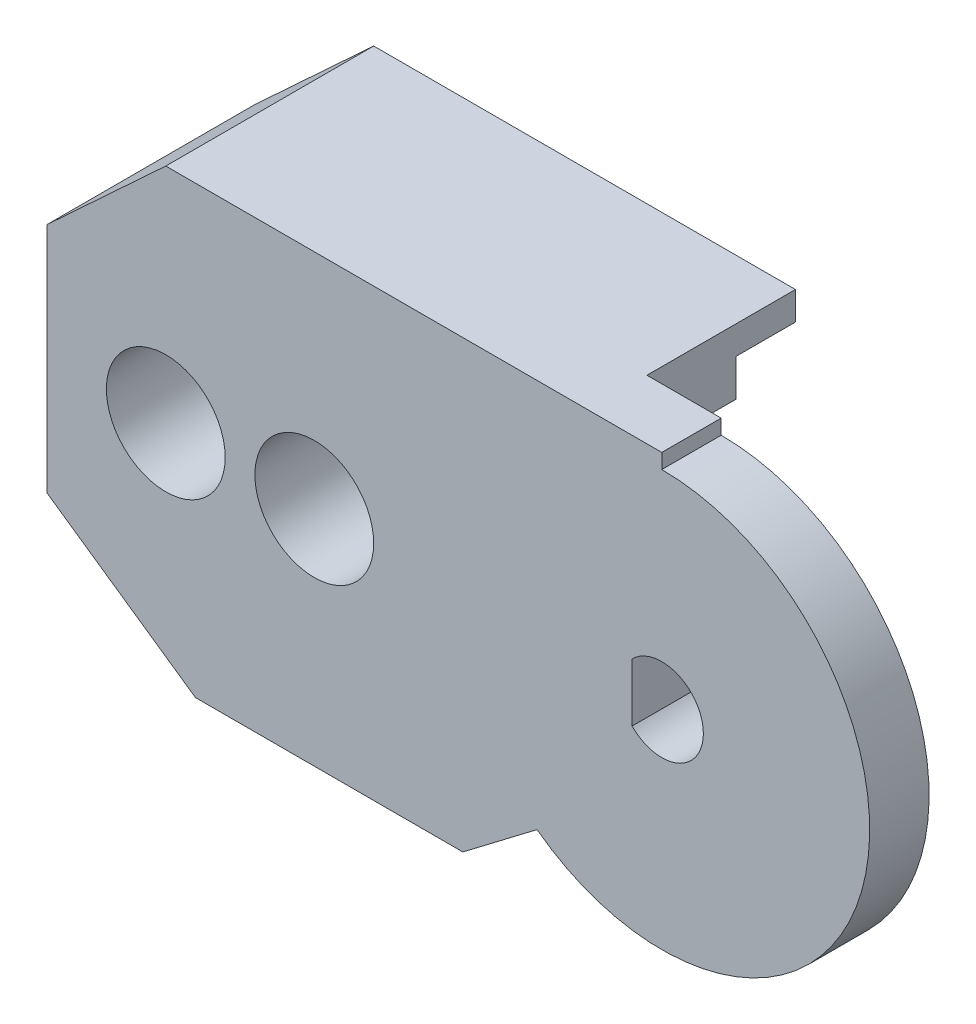
from build123d import *

# Parameters (mm, degrees)
BOSS_EXTRUDE1_DEPTH = 2
BOSS_EXTRUDE2_DEPTH = 5
SKETCH4_R           = 3.9
BOSS_EXTRUDE3_DEPTH = 1.2
CUT_EXTRUDE1_DEPTH  = 5
SKETCH7_W           = 1.5
SKETCH7_H           = 1.5
CUT_EXTRUDE2_DEPTH  = 5
SKETCH8_R           = 0.95
CUT_EXTRUDE3_DEPTH  = 8
SKETCH9_R           = 2
CUT_EXTRUDE4_DEPTH  = 3
SKETCH10_W          = 3
SKETCH10_H          = 1.25
CUT_EXTRUDE5_DEPTH  = 2


with BuildPart() as part:
    # Sketch1 → Boss-Extrude1 (new body)
    with BuildSketch(Plane.XY):
        with BuildLine():
            Line((-20.7, 3.793442666), (-20.7, -4.031648778))
            Line((-20.7, -4.031648778), (-15.7, -7.5))
            Line((-15.7, -7.5), (-6.7, -7.5))
            Line((-6.7, -7.5), (-4.2, -5.6))
            ThreePointArc((-4.2, -5.6), (3.130495168, -6.260990337), (7, 0))
            ThreePointArc((7, 0), (4.949747468, 4.949747468), (0, 7))
            Line((0, 7), (0, 7.5))
            Line((0, 7.5), (-16.7, 7.5))
            Line((-16.7, 7.5), (-20.7, 3.793442666))
        make_face()
    extrude(amount=BOSS_EXTRUDE1_DEPTH)

    # Sketch2 → Boss-Extrude2 (add)
    with BuildSketch(Plane(origin=(0, 0, 0), x_dir=(-1, 0, 0), z_dir=(0, 0, -1))):
        Polygon((16.7, 7.5), (20.7, 3.793442666), (20.7, -4.031648778), (15.7, -7.5), (6.7, -7.5), (6.7, -4.5), (7.7, -4.5), (7.7, 2), (5.5, 2), (5.5, 5.3), (2.5, 5.3), (2.5, 7.5), align=None)
    extrude(amount=BOSS_EXTRUDE2_DEPTH)

    # Sketch4 → Boss-Extrude3 (add)
    with BuildSketch(Plane(origin=(0, 0, 0), x_dir=(-1, 0, 0), z_dir=(0, 0, -1))):
        Circle(SKETCH4_R)
    extrude(amount=BOSS_EXTRUDE3_DEPTH)

    # Sketch5 → Cut-Extrude1 (cut)
    with BuildSketch(Plane(origin=(0, 0, -1.2), x_dir=(-1, 0, 0), z_dir=(0, 0, -1))):
        with BuildLine():
            Line((1, 0.979795897), (1, -0.979795897))
            ThreePointArc((1, -0.979795897), (-1.4, 0), (1, 0.979795897))
        make_face()
    extrude(amount=-CUT_EXTRUDE1_DEPTH, mode=Mode.SUBTRACT)

    # Sketch7 → Cut-Extrude2 (cut, along a direction that is not the sketch's normal)
    with BuildSketch(Plane.XZ.offset(7.5)):
        with Locations((-9.184228352, -5)):
            Rectangle(SKETCH7_W, SKETCH7_H)
    extrude(amount=-CUT_EXTRUDE2_DEPTH, dir=(-0.422651734, -0.906292178, 0), mode=Mode.SUBTRACT)

    # Sketch8 → Cut-Extrude3 (cut)
    with BuildSketch(Plane(origin=(0, 0, -5), x_dir=(-1, 0, 0), z_dir=(0, 0, -1))):
        with Locations((16.7, 0)):
            Circle(SKETCH8_R)
        with Locations((11.7, 0)):
            Circle(SKETCH8_R)
    extrude(amount=-CUT_EXTRUDE3_DEPTH, mode=Mode.SUBTRACT)

    # Sketch9 → Cut-Extrude4 (cut)
    with BuildSketch(Plane.XY.offset(2)):
        with Locations((-16.7, 0)):
            Circle(SKETCH9_R)
        with Locations((-11.7, 0)):
            Circle(SKETCH9_R)
    extrude(amount=-CUT_EXTRUDE4_DEPTH, mode=Mode.SUBTRACT)

    # Sketch10 → Cut-Extrude5 (cut)
    with BuildSketch(Plane(origin=(0, 0, -5), x_dir=(-1, 0, 0), z_dir=(0, 0, -1))):
        with Locations((4, 5.925)):
            Rectangle(SKETCH10_W, SKETCH10_H)
    extrude(amount=-CUT_EXTRUDE5_DEPTH, mode=Mode.SUBTRACT)


solid = part.part
